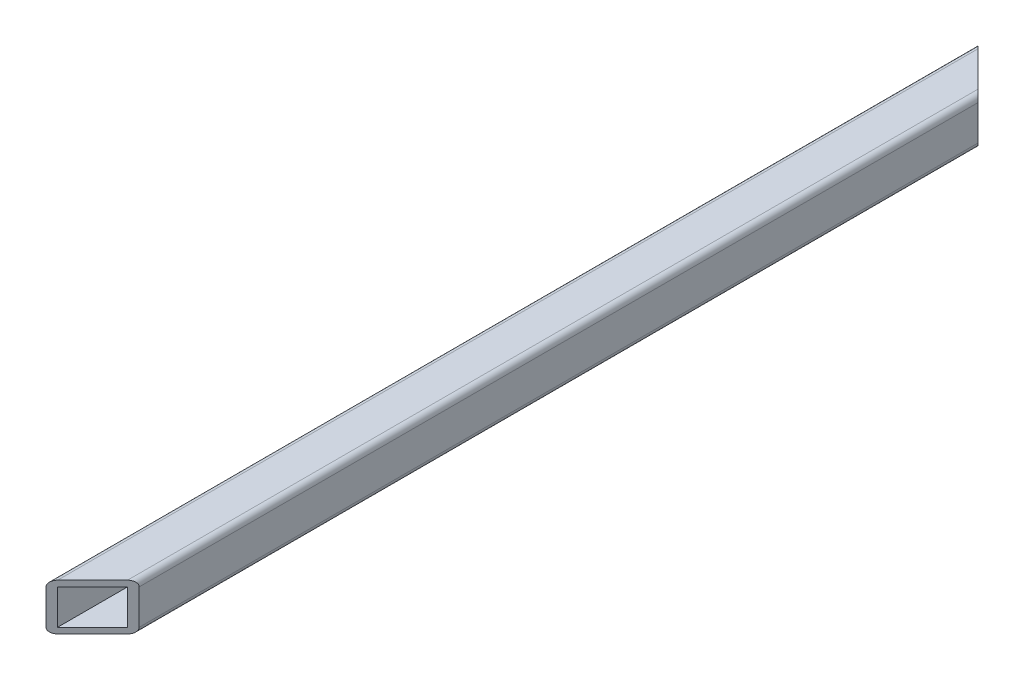
from build123d import *

# Parameters (mm, degrees)
SKETCH1_W           = 12.7
SKETCH1_H           = 12.7
SKETCH1_W_2         = 9.525
SKETCH1_H_2         = 9.525
BOSS_EXTRUDE1_DEPTH = 254
CUT_EXTRUDE1_DEPTH  = 13.7
FILLET1_R           = 1.5875
CUT_EXTRUDE2_REACH  = 14.7
SKETCH3_R           = 2.032


with BuildPart() as part:
    # Sketch1 → Boss-Extrude1 (new body)
    with BuildSketch(Plane.XY):
        with Locations((6.35, 6.35)):
            Rectangle(SKETCH1_W, SKETCH1_H)
        with Locations((6.35, 6.35)):
            Rectangle(SKETCH1_W_2, SKETCH1_H_2, mode=Mode.SUBTRACT)
    extrude(amount=BOSS_EXTRUDE1_DEPTH)

    # Sketch2 → Cut-Extrude1 (cut, through all)
    with BuildSketch(Plane(origin=(0, 12.7, 0), x_dir=(1, 0, 0), z_dir=(0, 1, 0))):
        Polygon((0, -254), (12.7, -254), (12.7, -241.3), align=None)
        Polygon((0, 0), (12.7, -12.7), (12.7, 0), align=None)
    extrude(amount=-CUT_EXTRUDE1_DEPTH, mode=Mode.SUBTRACT)

    # Fillet1
    fillet1_edges = [part.edges().sort_by_distance(p)[0] for p in [
        (12.7, 12.7, 127),
        (12.7, 0, 127),
        (0, 12.7, 127),
        (0, 0, 127),
    ]]
    fillet(fillet1_edges, radius=FILLET1_R)

    # Sketch3 → Cut-Extrude2 (cut, up to next)
    with BuildSketch(Plane.ZY, mode=Mode.PRIVATE) as cut_extrude2_sk1:
        with Locations((136.525, 6.35)):
            Circle(SKETCH3_R)
    cut_extrude2_tool1 = extrude(cut_extrude2_sk1.sketch, amount=-CUT_EXTRUDE2_REACH, mode=Mode.PRIVATE) & part.part
    add(cut_extrude2_tool1.solids().sort_by_distance((0, 6.35, 136.525))[0], mode=Mode.SUBTRACT)
    # Sketch3 → Cut-Extrude2 (cut, up to next)
    with BuildSketch(Plane.ZY, mode=Mode.PRIVATE) as cut_extrude2_sk2:
        with Locations((117.475, 6.35)):
            Circle(SKETCH3_R)
    cut_extrude2_tool2 = extrude(cut_extrude2_sk2.sketch, amount=-CUT_EXTRUDE2_REACH, mode=Mode.PRIVATE) & part.part
    add(cut_extrude2_tool2.solids().sort_by_distance((0, 6.35, 117.475))[0], mode=Mode.SUBTRACT)


solid = part.part
